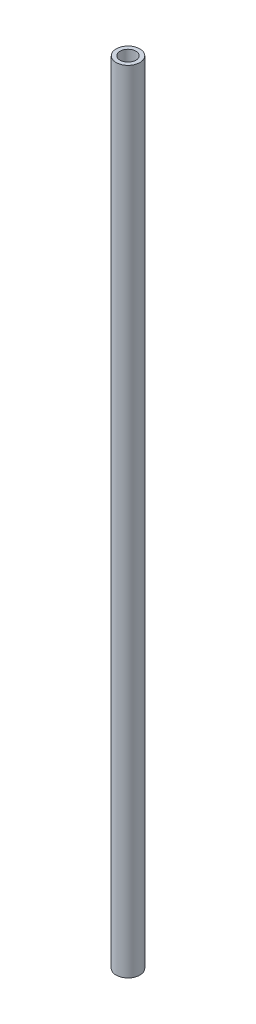
from build123d import *

# Parameters (mm, degrees)
SKETCH_1_R      = 3
SKETCH_1_R_2    = 2
EXTRUDE_1_DEPTH = 200
EXTRUDE_START   = -10
SKETCH_2_R      = 2
EXTRUDE_2_DEPTH = 3
SKETCH_3_R      = 2
EXTRUDE_3_DEPTH = 3


with BuildPart() as part:
    # 스케치1 → 보스-돌출1 (new body)
    with BuildSketch(Plane(origin=(0, 0, 0), x_dir=(1, 0, 0), z_dir=(0, 1, 0))):
        Circle(SKETCH_1_R)
        Circle(SKETCH_1_R_2, mode=Mode.SUBTRACT)
    extrude(amount=EXTRUDE_1_DEPTH)

    # 스케치2 → 보스-돌출2 (add)
    with BuildSketch(Plane.XZ.offset(EXTRUDE_START)):
        Circle(SKETCH_2_R)
    extrude(amount=-EXTRUDE_2_DEPTH)

    # 스케치3 → 보스-돌출3 (add)
    with BuildSketch(Plane(origin=(0, 200, 0), x_dir=(1, 0, 0), z_dir=(0, 1, 0)).offset(EXTRUDE_START)):
        Circle(SKETCH_3_R)
    extrude(amount=-EXTRUDE_3_DEPTH)


solid = part.part
